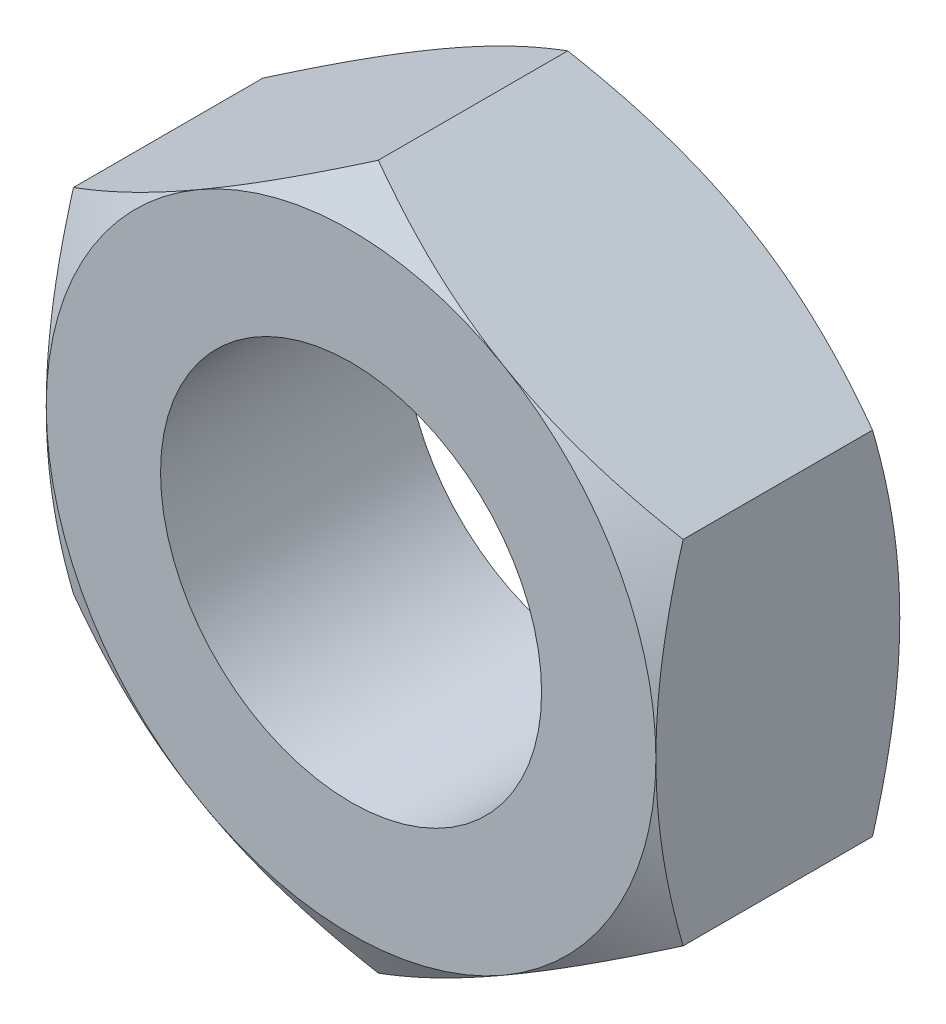
from build123d import *

# Parameters (mm, degrees)
EXTRUDE1_DEPTH     = 3.2
SKETCH2_R          = 2.5
CUT_EXTRUDE1_DEPTH = 4.2


with BuildPart() as part:
    # Sketch1 → Extrude1 (new body)
    with BuildSketch(Plane.XY):
        Polygon((0, 4.618802154), (-4, 2.309401077), (-4, -2.309401077), (0, -4.618802154), (4, -2.309401077), (4, 2.309401077), align=None)
    extrude(amount=EXTRUDE1_DEPTH)

    # Sketch2 → Cut-Extrude1 (cut, through all)
    with BuildSketch(Plane.XY.offset(3.2)):
        Circle(SKETCH2_R)
    extrude(amount=-CUT_EXTRUDE1_DEPTH, mode=Mode.SUBTRACT)

    # Sketch3 → Cut-Revolve1 (revolve, cut)
    with BuildSketch(Plane(origin=(0, 0, 0), x_dir=(0, 0, -1), z_dir=(1, 0, 0))):
        Polygon((-3.2, 5.618802154), (-2.265384141, 5.618802154), (-3.2, 4), align=None)
    cut_revolve1 = revolve(axis=Axis((0, 0, 0), (0, 0, 1)), mode=Mode.SUBTRACT)

    # Mirror1: Cut-Revolve1 across plane
    add(cut_revolve1.mirror(Plane.XY.offset(1.6)), mode=Mode.SUBTRACT)


solid = part.part
